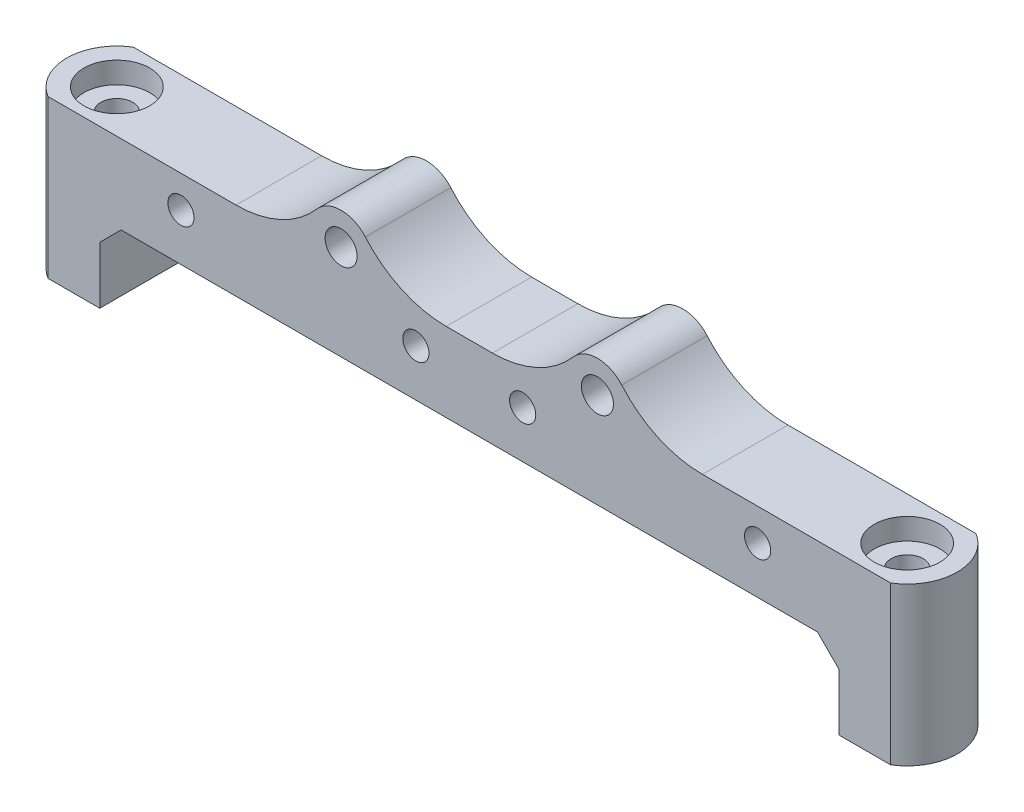
from build123d import *

# Parameters (mm, degrees)
SKETCH1_R               = 1
SKETCH1_R_2             = 1.5
BOSS_EXTRUDE1_DEPTH     = 8
SKETCH2_R               = 1.5
CUT_EXTRUDE1_DEPTH      = 20.25
BOSS_EXTRUDE2_DEPTH     = 14.75
SKETCH5_R               = 3.075
CUT_EXTRUDE2_DEPTH      = 5.5
CUT_EXTRUDE2_DEPTH_BACK = 2
CHAMFER2_SIZE           = 2
FILLET1_R               = 10
SKETCH6_R               = 1.225
CUT_EXTRUDE3_DEPTH      = 5


with BuildPart() as part:
    # Sketch1 → Boss-Extrude1 (new body)
    with BuildSketch(Plane.XY):
        with BuildLine():
            Line((34.6, 7.35), (34.6, 0))
            Line((34.6, 0), (39.45, 0))
            Line((39.45, 0), (39.45, 14.75))
            Line((39.45, 14.75), (14.598076211, 14.75))
            ThreePointArc((14.598076211, 14.75), (12, 19.25), (9.401923789, 14.75))
            Line((9.401923789, 14.75), (-9.401923789, 14.75))
            ThreePointArc((-9.401923789, 14.75), (-12, 19.25), (-14.598076211, 14.75))
            Line((-14.598076211, 14.75), (-39.45, 14.75))
            Line((-39.45, 14.75), (-39.45, 0))
            Line((-39.45, 0), (-34.6, 0))
            Line((-34.6, 0), (-34.6, 7.35))
            Line((-34.6, 7.35), (34.6, 7.35))
        make_face()
        with Locations((-5, 11.75)):
            Circle(SKETCH1_R, mode=Mode.SUBTRACT)
        with Locations((5, 11.75)):
            Circle(SKETCH1_R, mode=Mode.SUBTRACT)
        with Locations((27, 11.75)):
            Circle(SKETCH1_R, mode=Mode.SUBTRACT)
        with Locations((-27, 11.75)):
            Circle(SKETCH1_R, mode=Mode.SUBTRACT)
        with Locations((12, 16.25)):
            Circle(SKETCH1_R_2, mode=Mode.SUBTRACT)
        with Locations((-12, 16.25)):
            Circle(SKETCH1_R_2, mode=Mode.SUBTRACT)
    extrude(amount=BOSS_EXTRUDE1_DEPTH)

    # Sketch2 → Cut-Extrude1 (cut, through all)
    with BuildSketch(Plane.XZ):
        with Locations((-37, 4)):
            Circle(SKETCH2_R)
        with Locations((37, 4)):
            Circle(SKETCH2_R)
    extrude(amount=-CUT_EXTRUDE1_DEPTH, mode=Mode.SUBTRACT)

    # Sketch3 → Boss-Extrude2 (add)
    with BuildSketch(Plane(origin=(0, 14.75, 0), x_dir=(1, 0, 0), z_dir=(0, 1, 0))):
        with BuildLine():
            Line((39.45, -8), (39.45, 0))
            ThreePointArc((39.45, 0), (41.690682253, -4), (39.45, -8))
        make_face()
        with BuildLine():
            Line((-39.45, -8), (-39.45, 0))
            ThreePointArc((-39.45, 0), (-41.690682253, -4), (-39.45, -8))
        make_face()
    extrude(amount=-BOSS_EXTRUDE2_DEPTH)

    # Sketch5 → Cut-Extrude2 (cut, two sides)
    with BuildSketch(Plane(origin=(0, 14.75, 0), x_dir=(1, 0, 0), z_dir=(0, 1, 0))) as cut_extrude2_sk:
        with Locations((37, -4)):
            Circle(SKETCH5_R)
        with Locations((-37, -4)):
            Circle(SKETCH5_R)
    extrude(amount=CUT_EXTRUDE2_DEPTH, mode=Mode.SUBTRACT)
    extrude(cut_extrude2_sk.sketch, amount=-CUT_EXTRUDE2_DEPTH_BACK, mode=Mode.SUBTRACT)

    # Chamfer2
    chamfer2_edges = [part.edges().sort_by_distance(p)[0] for p in [
        (-34.6, 7.35, 4),
        (34.6, 7.35, 4),
    ]]
    chamfer(chamfer2_edges, length=CHAMFER2_SIZE)

    # Fillet1
    fillet1_edges = [part.edges().sort_by_distance(p)[0] for p in [
        (-14.598076211, 14.75, 4),
        (-9.401923789, 14.75, 4),
        (9.401923789, 14.75, 4),
        (14.598076211, 14.75, 4),
    ]]
    fillet(fillet1_edges, radius=FILLET1_R)

    # Sketch6 → Cut-Extrude3 (cut)
    with BuildSketch(Plane.XY.offset(8)):
        with Locations((-27, 11.75)):
            Circle(SKETCH6_R)
        with Locations((-5, 11.75)):
            Circle(SKETCH6_R)
        with Locations((5, 11.75)):
            Circle(SKETCH6_R)
        with Locations((27, 11.75)):
            Circle(SKETCH6_R)
    extrude(amount=-CUT_EXTRUDE3_DEPTH, mode=Mode.SUBTRACT)


solid = part.part
